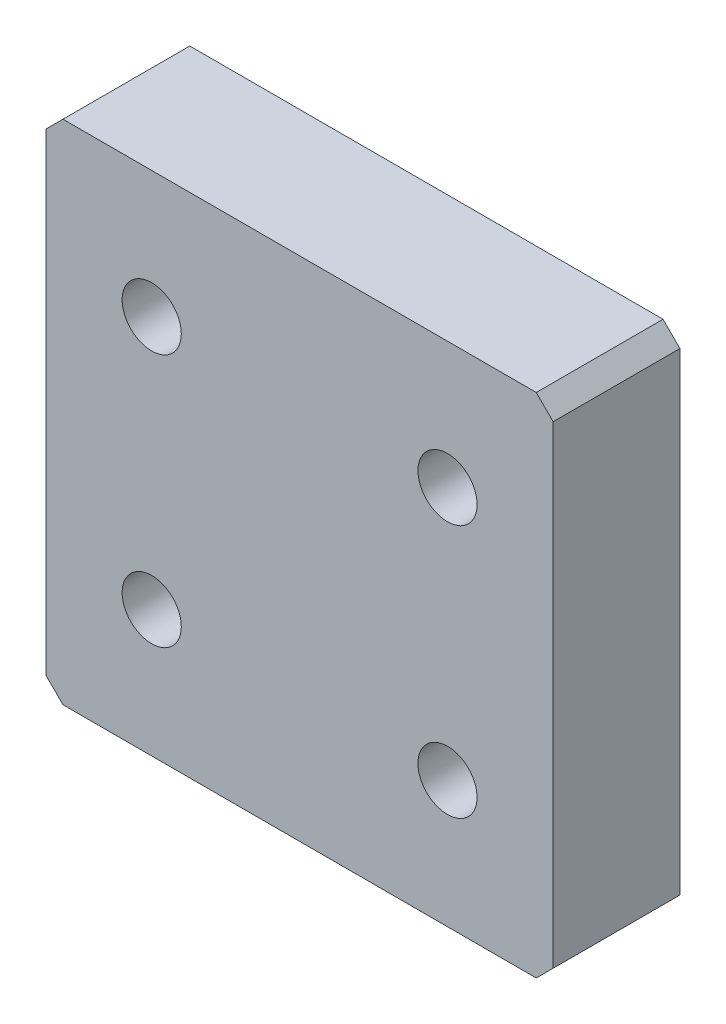
from build123d import *

# Parameters (mm, degrees)
SKETCH1_W           = 60
SKETCH1_H           = 60
SKETCH1_R           = 3.5
BOSS_EXTRUDE1_DEPTH = 15
CHAMFER1_SIZE       = 2


with BuildPart() as part:
    # Sketch1 → Boss-Extrude1 (new body)
    with BuildSketch(Plane.XY):
        Rectangle(SKETCH1_W, SKETCH1_H)
        with Locations((-17.5, 15)):
            Circle(SKETCH1_R, mode=Mode.SUBTRACT)
        with Locations((17.5, 15)):
            Circle(SKETCH1_R, mode=Mode.SUBTRACT)
        with Locations((-17.5, -15)):
            Circle(SKETCH1_R, mode=Mode.SUBTRACT)
        with Locations((17.5, -15)):
            Circle(SKETCH1_R, mode=Mode.SUBTRACT)
    extrude(amount=BOSS_EXTRUDE1_DEPTH)

    # Chamfer1
    chamfer1_edges = [part.edges().sort_by_distance(p)[0] for p in [
        (30, -30, 7.5),
        (-30, -30, 7.5),
        (-30, 30, 7.5),
        (30, 30, 7.5),
    ]]
    chamfer(chamfer1_edges, length=CHAMFER1_SIZE)


solid = part.part
